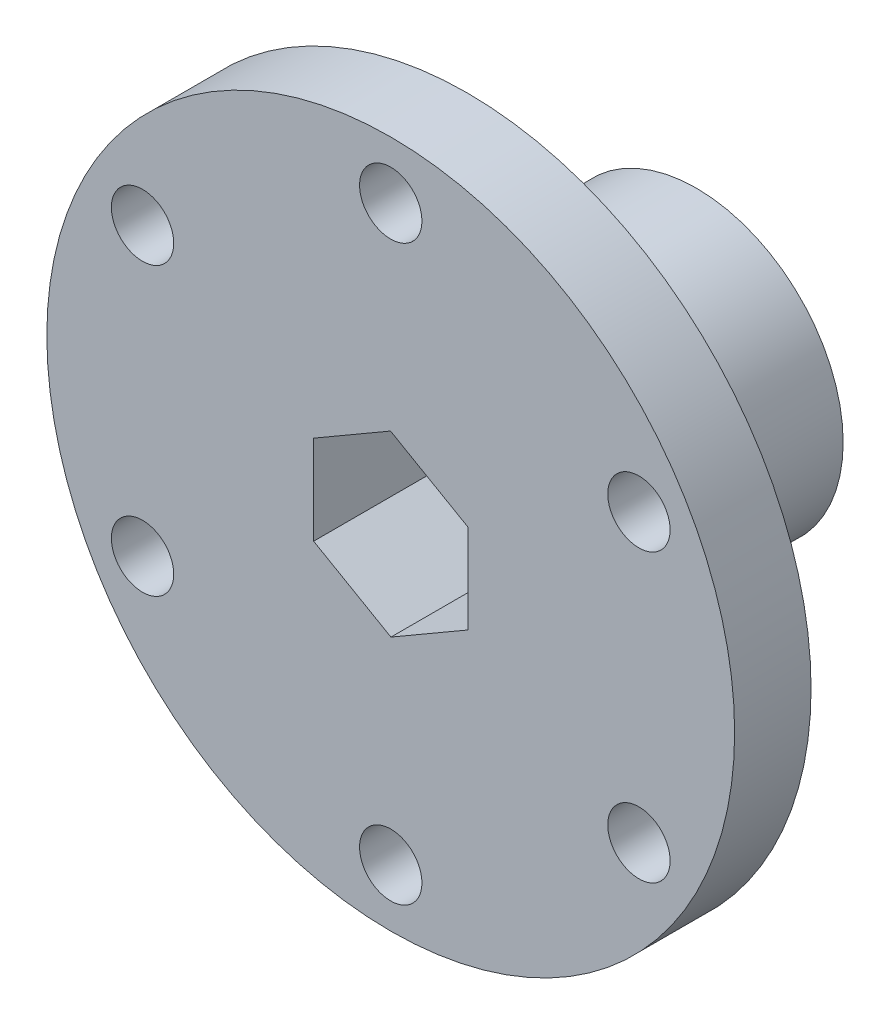
from build123d import *

# Parameters (mm, degrees)
SKETCH1_R           = 28.575
SKETCH1_R_2         = 2.5908
BOSS_EXTRUDE1_DEPTH = 6.35
SKETCH2_R           = 12.192
BOSS_EXTRUDE2_DEPTH = 19.05
CUT_EXTRUDE1_DEPTH  = 26.4


with BuildPart() as part:
    # Sketch1 → Boss-Extrude1 (new body)
    with BuildSketch(Plane.XY):
        Circle(SKETCH1_R)
        with Locations((0, 23.8125)):
            Circle(SKETCH1_R_2, mode=Mode.SUBTRACT)
        with Locations((20.622229928, 11.90625)):
            Circle(SKETCH1_R_2, mode=Mode.SUBTRACT)
        with Locations((20.622229928, -11.90625)):
            Circle(SKETCH1_R_2, mode=Mode.SUBTRACT)
        with Locations((0, -23.8125)):
            Circle(SKETCH1_R_2, mode=Mode.SUBTRACT)
        with Locations((-20.622229928, -11.90625)):
            Circle(SKETCH1_R_2, mode=Mode.SUBTRACT)
        with Locations((-20.622229928, 11.90625)):
            Circle(SKETCH1_R_2, mode=Mode.SUBTRACT)
    extrude(amount=BOSS_EXTRUDE1_DEPTH)

    # Sketch2 → Boss-Extrude2 (add)
    with BuildSketch(Plane(origin=(0, 0, 0), x_dir=(-1, 0, 0), z_dir=(0, 0, -1))):
        Circle(SKETCH2_R)
    extrude(amount=BOSS_EXTRUDE2_DEPTH)

    # Sketch3 → Cut-Extrude1 (cut, through all)
    with BuildSketch(Plane.XY.offset(6.35)):
        Polygon((6.42148496, -3.688971027), (6.405485103, 3.716683592), (-0.015999857, 7.405654619), (-6.42148496, 3.688971027), (-6.405485103, -3.716683592), (0.015999857, -7.405654619), align=None)
    extrude(amount=-CUT_EXTRUDE1_DEPTH, mode=Mode.SUBTRACT)


solid = part.part
